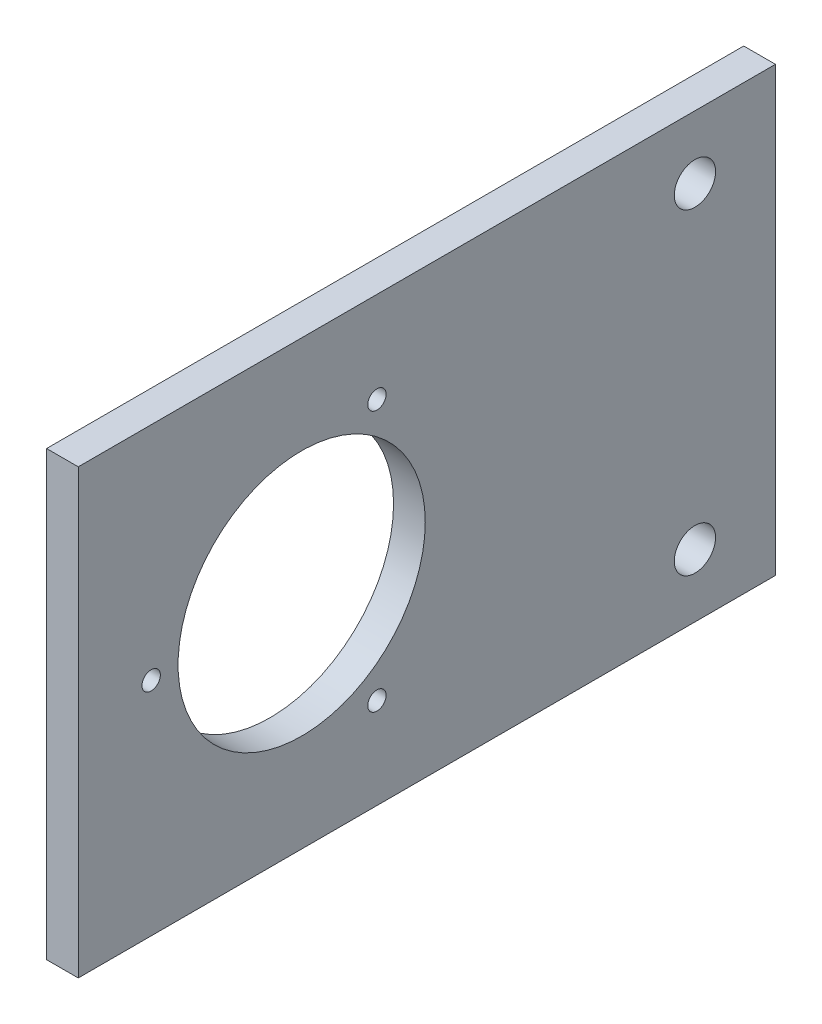
from build123d import *

# Parameters (mm, degrees)
SKETCH1_W           = 69.85
SKETCH1_H           = 110
SKETCH1_R           = 19.5
SKETCH1_R_2         = 3.25755
SKETCH1_R_3         = 1.45
BOSS_EXTRUDE1_DEPTH = 5


with BuildPart() as part:
    # Sketch1 → Boss-Extrude1 (new body)
    with BuildSketch(Plane.YZ):
        Rectangle(SKETCH1_W, SKETCH1_H)
        with Locations((0, 19.75)):
            Circle(SKETCH1_R, mode=Mode.SUBTRACT)
        with Locations((-25, -42.3)):
            Circle(SKETCH1_R_2, mode=Mode.SUBTRACT)
        with Locations((25, -42.3)):
            Circle(SKETCH1_R_2, mode=Mode.SUBTRACT)
        with Locations((-20.56810334, 7.875)):
            Circle(SKETCH1_R_3, mode=Mode.SUBTRACT)
        with Locations((20.56810334, 7.875)):
            Circle(SKETCH1_R_3, mode=Mode.SUBTRACT)
        with Locations((0, 43.5)):
            Circle(SKETCH1_R_3, mode=Mode.SUBTRACT)
    extrude(amount=BOSS_EXTRUDE1_DEPTH)


solid = part.part
